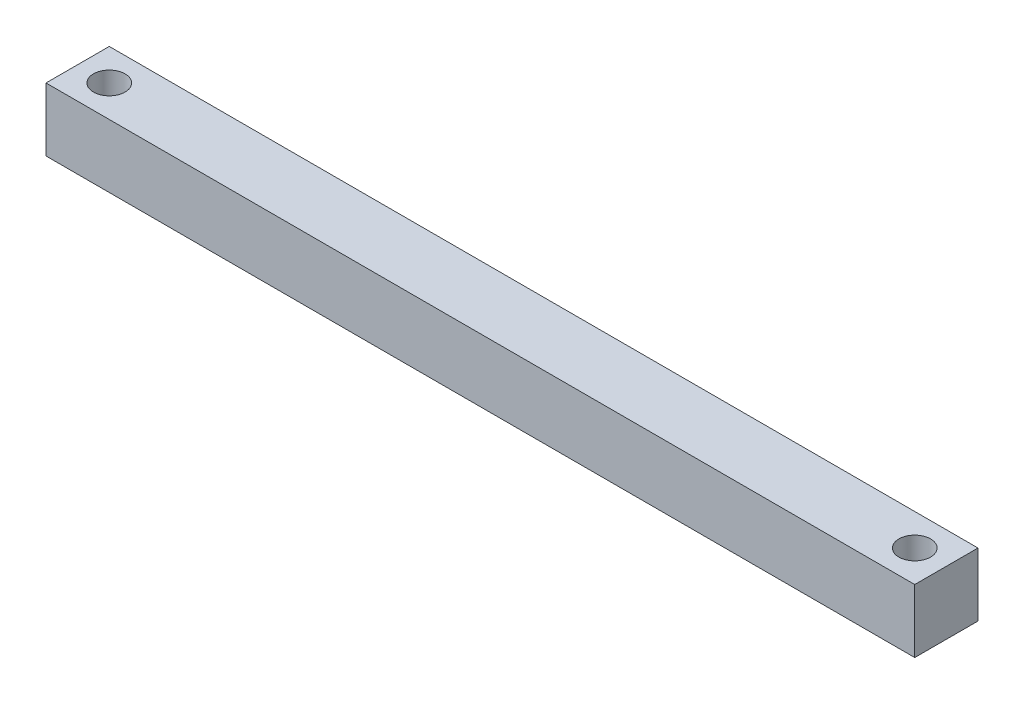
from build123d import *

# Parameters (mm, degrees)
SKETCH1_W           = 25.4
SKETCH1_H           = 25.4
BOSS_EXTRUDE1_DEPTH = 348.829051578
SKETCH2_R           = 6.35
CUT_EXTRUDE1_DEPTH  = 26.4


with BuildPart() as part:
    # Sketch1 → Boss-Extrude1 (new body)
    with BuildSketch(Plane(origin=(0, 0, 0), x_dir=(0, 0, -1), z_dir=(1, 0, 0))):
        Rectangle(SKETCH1_W, SKETCH1_H)
    extrude(amount=-BOSS_EXTRUDE1_DEPTH)

    # Sketch2 → Cut-Extrude1 (cut, through all)
    with BuildSketch(Plane(origin=(0, 12.7, 0), x_dir=(1, 0, 0), z_dir=(0, 1, 0))):
        with Locations((-336.129051578, 0)):
            Circle(SKETCH2_R)
        with Locations((-12.7, 0)):
            Circle(SKETCH2_R)
    extrude(amount=-CUT_EXTRUDE1_DEPTH, mode=Mode.SUBTRACT)


solid = part.part
